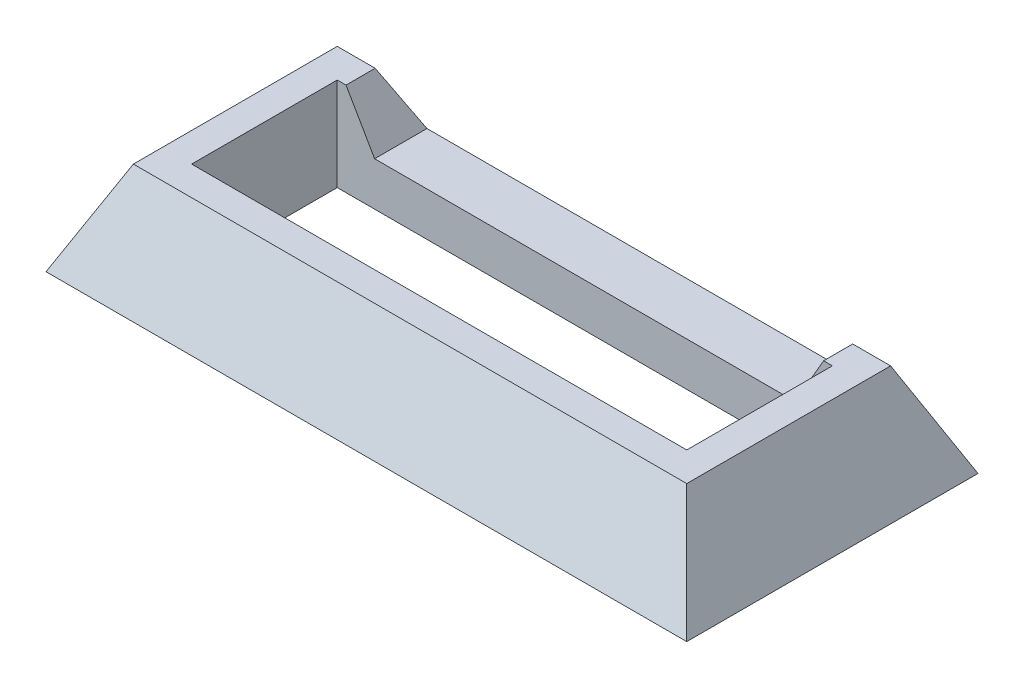
from build123d import *

# Parameters (mm, degrees)
CROQUIS2_W            = 19
CROQUIS2_H            = 7
CROQUIS1_W            = 22
CROQUIS1_H            = 10
CORTAR_EXTRUIR1_REACH = 5.2
CROQUIS1_3_W          = 17
CROQUIS1_3_H          = 5
CORTAR_EXTRUIR2_REACH = 7


with BuildPart() as part:
    # Croquis2 → Recubrir1 section 0
    with BuildSketch(Plane(origin=(0, 3.2, 0), x_dir=(1, 0, 0), z_dir=(0, 1, 0))):
        Rectangle(CROQUIS2_W, CROQUIS2_H)
    # Croquis1 → Recubrir1 section 1
    with BuildSketch(Plane(origin=(0, 0, 0), x_dir=(1, 0, 0), z_dir=(0, 1, 0))):
        Rectangle(CROQUIS1_W, CROQUIS1_H)
    loft()

    # Croquis1_3 → Cortar-Extruir1 (cut, up to next)
    with BuildSketch(Plane(origin=(0, 0, 0), x_dir=(1, 0, 0), z_dir=(0, 1, 0)), mode=Mode.PRIVATE) as cortar_extruir1_sk1:
        Rectangle(CROQUIS1_3_W, CROQUIS1_3_H)
    cortar_extruir1_tool1 = extrude(cortar_extruir1_sk1.sketch, amount=CORTAR_EXTRUIR1_REACH, mode=Mode.PRIVATE) & part.part
    add(cortar_extruir1_tool1.solids().sort_by_distance((0, 0, 0))[0], mode=Mode.SUBTRACT)

    # Croquis4 → Cortar-Extruir2 (cut, up to next)
    with BuildSketch(Plane.XY, mode=Mode.PRIVATE) as cortar_extruir2_sk1:
        Polygon((7.216878365, 1.5), (14.43375673, 14), (7.216878365, 26.5), (-7.216878365, 26.5), (-14.43375673, 14), (-7.216878365, 1.5), align=None)
    cortar_extruir2_tool1 = extrude(cortar_extruir2_sk1.sketch, amount=-CORTAR_EXTRUIR2_REACH, mode=Mode.PRIVATE) & part.part
    add(cortar_extruir2_tool1.solids().sort_by_distance((0, 14, 0))[0], mode=Mode.SUBTRACT)


solid = part.part
